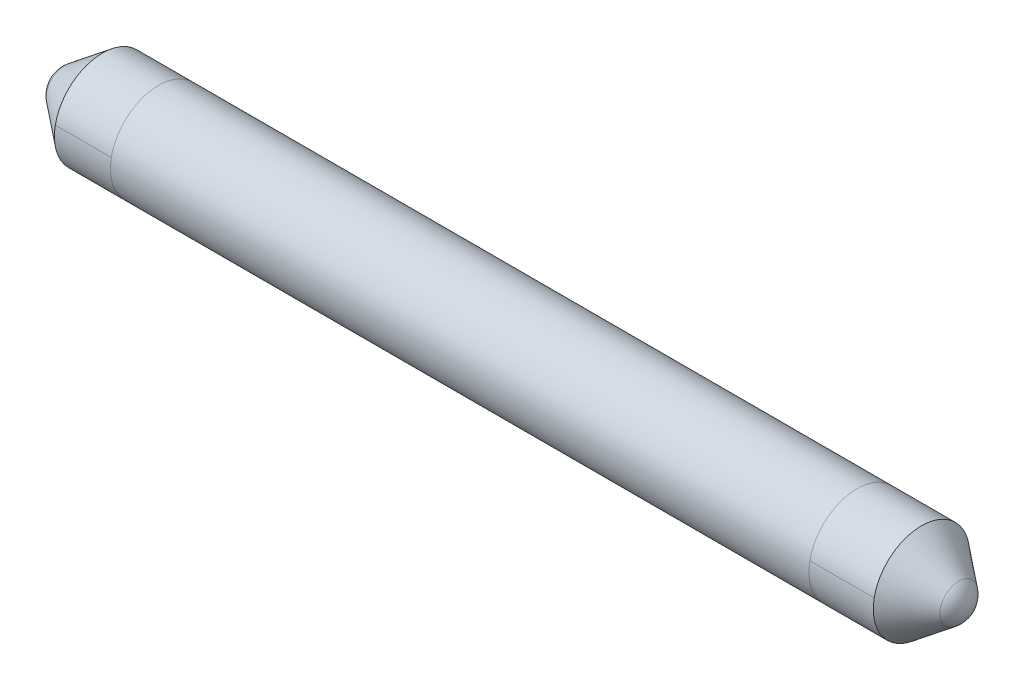
from build123d import *


with BuildPart() as part:
    # Sketch1 → Base-Revolve (revolve)
    with BuildSketch(Plane.XY):
        with BuildLine():
            Line((0, -101.643982593), (-189.372661972, -101.643982593))
            ThreePointArc((-189.372661972, -101.643982593), (-188.359470195, -97.257950448), (-185.525206377, -93.760696644))
            Line((-185.525206377, -93.760696644), (-170, -81.643982593))
            Line((-170, -81.643982593), (-160, -81.643982593))
            Line((-160, -81.643982593), (-100, -81.643982593))
            Line((-100, -81.643982593), (0, -81.643982593))
            Line((0, -81.643982593), (0, -101.643982593))
        make_face()
    base_revolve = revolve(axis=Axis((0, -101.643982593, 0), (-1, 0, 0)))

    # Mirror1: Base-Revolve across plane
    add(base_revolve.mirror(Plane(origin=(0, 0, 0), x_dir=(0, 0, 1), z_dir=(1, 0, 0))))


solid = part.part
